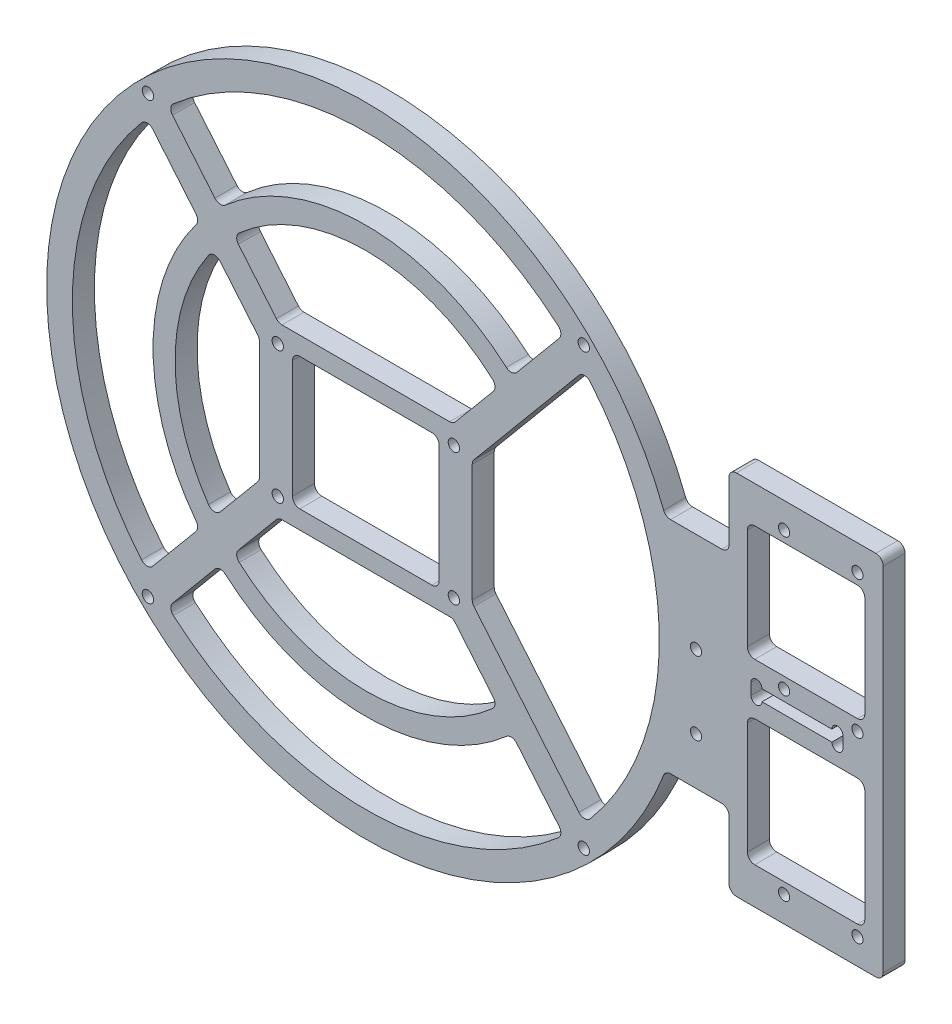
from build123d import *

# Parameters (mm, degrees)
SKETCH_1_R           = 87
SKETCH_1_R_2         = 1.55
EXTRUDE_1_DEPTH      = 6
SKETCH_2_R           = 1.55
CUT_EXTRUDE_1_DEPTH  = 40
SKETCH_3_W           = 100
SKETCH_3_H           = 60
EXTRUDE_2_DEPTH      = 6
CUT_EXTRUDE_2_DEPTH  = 40
SKETCH_5_R           = 58
SKETCH_5_R_2         = 52
EXTRUDE_3_DEPTH      = 6
CUT_EXTRUDE_3_DEPTH  = 70
FILLET_2_R           = 2
SKETCH_7_W           = 38
SKETCH_7_H           = 100
EXTRUDE_4_DEPTH      = 6
SKETCH_8_W           = 40
SKETCH_8_H           = 36
CUT_EXTRUDE_4_DEPTH  = 20
FILLET_3_R           = 2
SKETCH_9_R           = 1.525
CUT_EXTRUDE_5_DEPTH  = 80
SKETCH_10_R          = 1.525
CUT_EXTRUDE_6_DEPTH  = 80
SKETCH_11_W          = 25.06
SKETCH_11_H          = 3.06
CUT_EXTRUDE_7_DEPTH  = 30
SKETCH_12_R          = 1.505
CUT_EXTRUDE_8_DEPTH  = 60
SKETCH_13_W          = 4
SKETCH_13_H          = 100
EXTRUDE_5_DEPTH      = 6
SKETCH_14_R          = 1.525
CUT_EXTRUDE_9_DEPTH  = 6
SKETCH_15_W          = 32
SKETCH_15_H          = 31.510193749
SKETCH_15_H_2        = 34.459806251
CUT_EXTRUDE_10_DEPTH = 6
FILLET_4_R           = 2


with BuildPart() as part:
    # 草图1 → 凸台-拉伸1 (new body)
    with BuildSketch(Plane.XY):
        Circle(SKETCH_1_R)
        with Locations((24, 18)):
            Circle(SKETCH_1_R_2, mode=Mode.SUBTRACT)
        with Locations((-24, 18)):
            Circle(SKETCH_1_R_2, mode=Mode.SUBTRACT)
        with Locations((-24, -18)):
            Circle(SKETCH_1_R_2, mode=Mode.SUBTRACT)
        with Locations((24, -18)):
            Circle(SKETCH_1_R_2, mode=Mode.SUBTRACT)
    extrude(amount=EXTRUDE_1_DEPTH)

    # 草图2 → 切除-拉伸1 (cut)
    with BuildSketch(Plane.XY.offset(6)):
        with Locations((59.39696962, 59.39696962)):
            Circle(SKETCH_2_R)
        with Locations((59.39696962, -59.39696962)):
            Circle(SKETCH_2_R)
        with Locations((-59.39696962, -59.39696962)):
            Circle(SKETCH_2_R)
        with Locations((-59.39696962, 59.39696962)):
            Circle(SKETCH_2_R)
    extrude(amount=-CUT_EXTRUDE_1_DEPTH, mode=Mode.SUBTRACT)

    # 草图3 → 凸台-拉伸2 (add)
    with BuildSketch(Plane.XY.offset(6)):
        with Locations((87, 0)):
            Rectangle(SKETCH_3_W, SKETCH_3_H)
    extrude(amount=-EXTRUDE_2_DEPTH)

    # 草图4 → 切除-拉伸2 (cut)
    with BuildSketch(Plane(origin=(0, 0, 0), x_dir=(-1, 0, 0), z_dir=(0, 0, -1))):
        with BuildLine():
            Line((23.788509037, -23), (-23.788509037, -23))
            Line((-23.788509037, -23), (-53.929203709, -59.090109048))
            ThreePointArc((-53.929203709, -59.090109048), (0, -80), (53.929203709, -59.090109048))
            Line((53.929203709, -59.090109048), (23.788509037, -23))
        make_face()
        with BuildLine():
            Line((29, 16.759822751), (29, -16.759822751))
            Line((29, -16.759822751), (59.584985836, -53.38192075))
            ThreePointArc((59.584985836, -53.38192075), (74.722148212, -28.576223798), (80, 0))
            ThreePointArc((80, 0), (74.722148212, 28.576223798), (59.584985836, 53.38192075))
            Line((59.584985836, 53.38192075), (29, 16.759822751))
        make_face()
        with BuildLine():
            Line((-59.584985836, -53.38192075), (-29, -16.759822751))
            Line((-29, -16.759822751), (-29, 16.759822751))
            Line((-29, 16.759822751), (-59.584985836, 53.38192075))
            ThreePointArc((-59.584985836, 53.38192075), (-80, 0), (-59.584985836, -53.38192075))
        make_face()
        with BuildLine():
            Line((-53.929203709, 59.090109048), (-23.788509037, 23))
            Line((-23.788509037, 23), (23.788509037, 23))
            Line((23.788509037, 23), (53.929203709, 59.090109048))
            ThreePointArc((53.929203709, 59.090109048), (0, 80), (-53.929203709, 59.090109048))
        make_face()
    extrude(amount=-CUT_EXTRUDE_2_DEPTH, mode=Mode.SUBTRACT)

    # 草图5 → 凸台-拉伸3 (add)
    with BuildSketch(Plane(origin=(0, 0, 0), x_dir=(-1, 0, 0), z_dir=(0, 0, -1))):
        Circle(SKETCH_5_R)
        Circle(SKETCH_5_R_2, mode=Mode.SUBTRACT)
    extrude(amount=-EXTRUDE_3_DEPTH)

    # 草图6 → 切除-拉伸3 (cut)
    with BuildSketch(Plane(origin=(0, 0, 0), x_dir=(-1, 0, 0), z_dir=(0, 0, -1))):
        with BuildLine():
            Line((-45.276728704, 36.249383966), (-41.343228936, 31.539458162))
            Line((-41.343228936, 31.539458162), (-41.343228936, -31.539458162))
            Line((-41.343228936, -31.539458162), (-45.276728704, -36.249383966))
            ThreePointArc((-45.276728704, -36.249383966), (-58, 0), (-45.276728704, 36.249383966))
        make_face()
    extrude(amount=-CUT_EXTRUDE_3_DEPTH, mode=Mode.SUBTRACT)

    # 圆角2
    fillet_2_edges = [part.edges().sort_by_distance(p)[0] for p in [
        (-23.788509037, 23, 3),
        (23.788509037, 23, 3),
        (53.929203709, 59.090109048, 3),
        (53.929203709, -59.090109048, 3),
        (23.788509037, -23, 3),
        (-23.788509037, -23, 3),
        (-53.929203709, -59.090109048, 3),
        (-41.343228936, 31.539458162, 3),
        (-45.276728704, 36.249383966, 3),
        (39.808222335, -42.181814026, 3),
        (-39.808222335, 42.181814026, 3),
        (39.808222335, 42.181814026, 3),
        (-39.808222335, -42.181814026, 3),
        (35.954274067, -37.567142243, 3),
        (-35.954274067, -37.567142243, 3),
        (-35.954274067, 37.567142243, 3),
        (35.954274067, 37.567142243, 3),
        (-41.343228936, -31.539458162, 3),
        (-45.276728704, -36.249383966, 3),
        (-59.584985836, -53.38192075, 3),
        (-29, -16.759822751, 3),
        (-29, 16.759822751, 3),
        (-59.584985836, 53.38192075, 3),
        (59.584985836, 53.38192075, 3),
        (29, 16.759822751, 3),
        (29, -16.759822751, 3),
        (59.584985836, -53.38192075, 3),
        (-53.929203709, 59.090109048, 3),
    ]]
    fillet(fillet_2_edges, radius=FILLET_2_R)

    # 草图7 → 凸台-拉伸4 (add)
    with BuildSketch(Plane(origin=(0, 0, 0), x_dir=(-1, 0, 0), z_dir=(0, 0, -1))):
        with Locations((-118, 0)):
            Rectangle(SKETCH_7_W, SKETCH_7_H)
    extrude(amount=-EXTRUDE_4_DEPTH)

    # 草图8 → 切除-拉伸4 (cut, symmetric)
    with BuildSketch(Plane(origin=(0, 0, 0), x_dir=(-1, 0, 0), z_dir=(0, 0, -1))):
        Rectangle(SKETCH_8_W, SKETCH_8_H)
    extrude(amount=CUT_EXTRUDE_4_DEPTH, both=True, mode=Mode.SUBTRACT)

    # 圆角3
    fillet_3_edges = [part.edges().sort_by_distance(p)[0] for p in [
        (-20, 18, 3),
        (-20, -18, 3),
        (20, -18, 3),
        (20, 18, 3),
    ]]
    fillet(fillet_3_edges, radius=FILLET_3_R)

    # 草图9 → 切除-拉伸5 (cut)
    with BuildSketch(Plane(origin=(0, 0, 0), x_dir=(-1, 0, 0), z_dir=(0, 0, -1))):
        with Locations((-134, -43)):
            Circle(SKETCH_9_R)
        with Locations((-114, -43)):
            Circle(SKETCH_9_R)
        with Locations((-114, 43)):
            Circle(SKETCH_9_R)
        with Locations((-134, 43)):
            Circle(SKETCH_9_R)
    extrude(amount=-CUT_EXTRUDE_5_DEPTH, mode=Mode.SUBTRACT)

    # 草图10 → 切除-拉伸6 (cut)
    with BuildSketch(Plane.XY.offset(6)):
        with Locations((90, -17.118993381)):
            Circle(SKETCH_10_R)
        with Locations((90, 2.881006619)):
            Circle(SKETCH_10_R)
    extrude(amount=-CUT_EXTRUDE_6_DEPTH, mode=Mode.SUBTRACT)

    # 草图11 → 切除-拉伸7 (cut)
    with BuildSketch(Plane(origin=(0, 0, 0), x_dir=(-1, 0, 0), z_dir=(0, 0, -1))):
        with Locations((-117.5, 0.989806251)):
            Rectangle(SKETCH_11_W, SKETCH_11_H)
    extrude(amount=-CUT_EXTRUDE_7_DEPTH, mode=Mode.SUBTRACT)

    # 草图12 → 切除-拉伸8 (cut)
    with BuildSketch(Plane(origin=(0, 0, 0), x_dir=(-1, 0, 0), z_dir=(0, 0, -1))):
        with Locations((-128.525, 2.519806251)):
            Circle(SKETCH_12_R)
        with Locations((-128.525, -0.540193749)):
            Circle(SKETCH_12_R)
        with Locations((-106.475, 2.519806251)):
            Circle(SKETCH_12_R)
        with Locations((-106.475, -0.540193749)):
            Circle(SKETCH_12_R)
    extrude(amount=-CUT_EXTRUDE_8_DEPTH, mode=Mode.SUBTRACT)

    # 草图13 → 凸台-拉伸5 (add)
    with BuildSketch(Plane(origin=(0, 0, 0), x_dir=(-1, 0, 0), z_dir=(0, 0, -1))):
        with Locations((-139, 0)):
            Rectangle(SKETCH_13_W, SKETCH_13_H)
    extrude(amount=-EXTRUDE_5_DEPTH)

    # 草图14 → 切除-拉伸9 (cut)
    with BuildSketch(Plane(origin=(0, 0, 0), x_dir=(-1, 0, 0), z_dir=(0, 0, -1))):
        with Locations((-134, 5.489806251)):
            Circle(SKETCH_14_R)
        with Locations((-114, 5.489806251)):
            Circle(SKETCH_14_R)
    extrude(amount=-CUT_EXTRUDE_9_DEPTH, mode=Mode.SUBTRACT)

    # 草图15 → 切除-拉伸10 (cut)
    with BuildSketch(Plane.XY.offset(6)):
        with Locations((120, 24.244903126)):
            Rectangle(SKETCH_15_W, SKETCH_15_H)
        with Locations((120, -22.770096874)):
            Rectangle(SKETCH_15_W, SKETCH_15_H_2)
    extrude(amount=-CUT_EXTRUDE_10_DEPTH, mode=Mode.SUBTRACT)

    # 圆角4
    fillet_4_edges = [part.edges().sort_by_distance(p)[0] for p in [
        (99, 30, 3),
        (99, -30, 3),
        (81.663945533, 30, 3),
        (99, 50, 3),
        (99, -50, 3),
        (81.663945533, -30, 3),
        (141, 50, 3),
        (141, -50, 3),
        (136, 40, 3),
        (136, 8.489806251, 3),
        (104, 8.489806251, 3),
        (104, 40, 3),
        (136, -5.540193749, 3),
        (136, -40, 3),
        (104, -40, 3),
        (104, -5.540193749, 3),
    ]]
    fillet(fillet_4_edges, radius=FILLET_4_R)


solid = part.part
